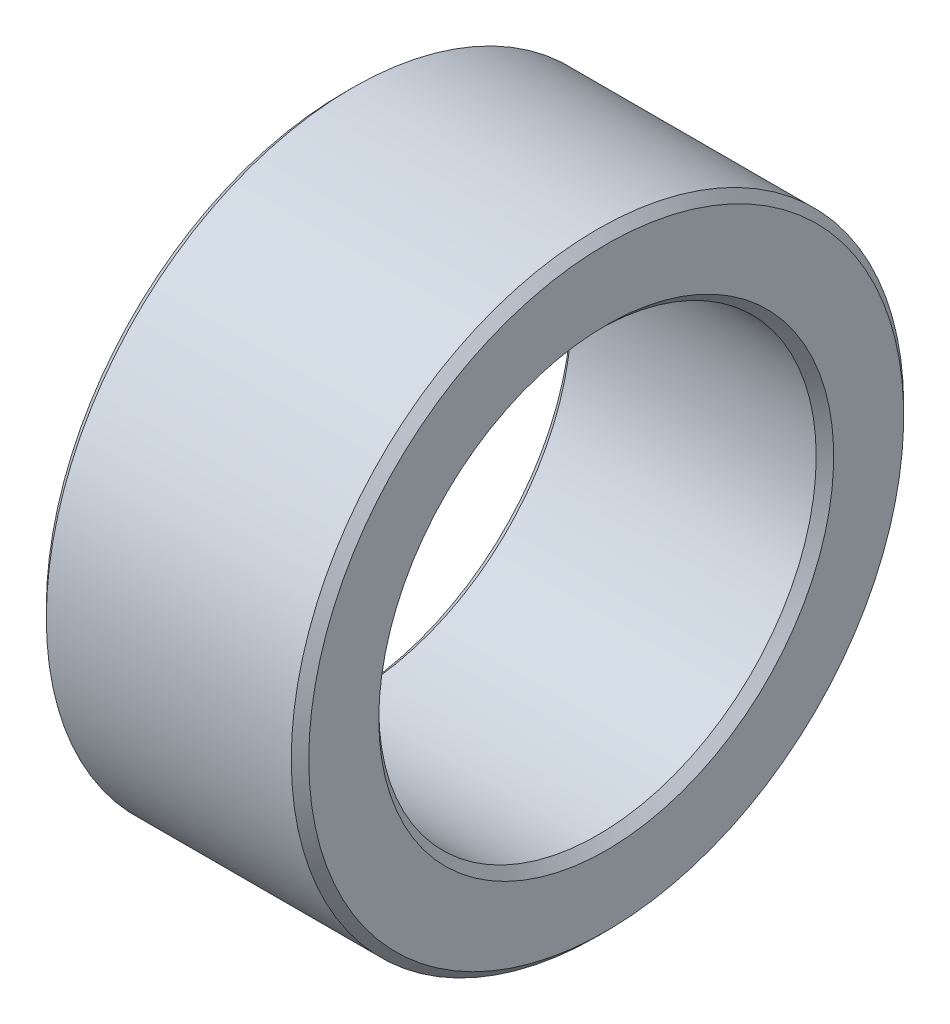
from build123d import *


with BuildPart() as part:
    # Эскиз1 → Повернуть1 (revolve)
    with BuildSketch(Plane.XY):
        Polygon((0.2, 5), (5.8, 5), (6, 5.2), (6, 6.8), (5.8, 7), (0.2, 7), (0, 6.8), (0, 5.2), align=None)
    revolve(axis=Axis((0, 0, 0), (1, 0, 0)))


solid = part.part
